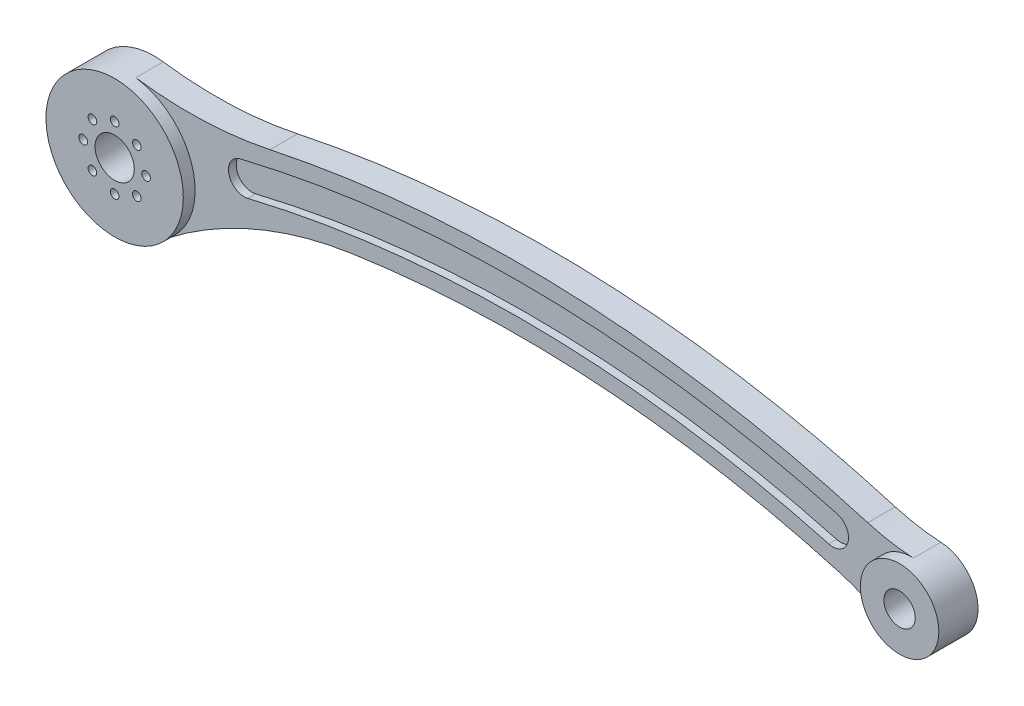
from build123d import *

# Parameters (mm, degrees)
SKETCH1_R                = 5
SKETCH1_R_2              = 4
BOSS_EXTRUDE1_DEPTH      = 10
FILLET1_R                = 100
FILLET3_R                = 50
BOSS_EXTRUDE2_DEPTH      = 5
CUT_EXTRUDE1_DEPTH       = 3
M2_CLEARANCE_HOLE2_D     = 2.2
M2_CLEARANCE_HOLE2_DEPTH = 10


with BuildPart() as part:
    # Sketch1 → Boss-Extrude1 (new body)
    with BuildSketch(Plane.XY):
        with BuildLine():
            ThreePointArc((12.332289397, 12.416305338), (-16.645203494, -5.40251799), (17.2733755, -2.807222621))
            ThreePointArc((17.2733755, -2.807222621), (104.699737116, 9.220908362), (191.757044964, -5.238337488))
            ThreePointArc((191.757044964, -5.238337488), (209.474645485, -2.773362317), (196.872940476, 9.922562291))
            ThreePointArc((196.872940476, 9.922562291), (104.792499107, 25.221141559), (12.332289397, 12.416305338))
        make_face()
        Circle(SKETCH1_R, mode=Mode.SUBTRACT)
        with Locations((199.999550741, 0.423914585)):
            Circle(SKETCH1_R_2, mode=Mode.SUBTRACT)
        with BuildLine():
            ThreePointArc((30.935149345, 4.991193321), (105.08187222, 13.215793431), (178.947951069, 2.766728612))
            ThreePointArc((178.947951069, 2.766728612), (183.85884318, 5.57442138), (181.051150412, 10.485313491))
            ThreePointArc((181.051150412, 10.485313491), (105.20208958, 21.214890117), (29.064850655, 12.769495373))
            ThreePointArc((29.064850655, 12.769495373), (26.110848974, 7.945195001), (30.935149345, 4.991193321))
        make_face(mode=Mode.SUBTRACT)
    extrude(amount=BOSS_EXTRUDE1_DEPTH)

    # Fillet1
    fillet1_edges = [part.edges().sort_by_distance(p)[0] for p in [
        (17.2733755, -2.807222621, 5),
        (12.332289397, 12.416305338, 5),
    ]]
    fillet(fillet1_edges, radius=FILLET1_R)

    # Fillet3
    fillet3_edges = [part.edges().sort_by_distance(p)[0] for p in [
        (196.872940476, 9.922562291, 5),
        (191.757044964, -5.238337488, 5),
    ]]
    fillet(fillet3_edges, radius=FILLET3_R)

    # Sketch2 → Boss-Extrude2 (add)
    with BuildSketch(Plane(origin=(0, 0, 0), x_dir=(-1, 0, 0), z_dir=(0, 0, -1))):
        with BuildLine():
            ThreePointArc((-30.935149345, 4.991193321), (-26.110848974, 7.945195001), (-29.064850655, 12.769495373))
            ThreePointArc((-29.064850655, 12.769495373), (-105.20208958, 21.214890117), (-181.051150412, 10.485313491))
            ThreePointArc((-181.051150412, 10.485313491), (-183.85884318, 5.57442138), (-178.947951069, 2.766728612))
            ThreePointArc((-178.947951069, 2.766728612), (-105.08187222, 13.215793431), (-30.935149345, 4.991193321))
        make_face()
    extrude(amount=-BOSS_EXTRUDE2_DEPTH)

    # Sketch3 → Cut-Extrude1 (cut)
    with BuildSketch(Plane.XY.offset(10)):
        with BuildLine():
            ThreePointArc((10.719889508, -13.832352256), (16.904607487, 4.525952466), (2.374455951, 17.338164809))
            ThreePointArc((2.374455951, 17.338164809), (19.536178227, 16.477975853), (36.591800033, 18.568526337))
            ThreePointArc((36.591800033, 18.568526337), (113.1236291, 24.996521405), (188.887012749, 12.412814518))
            ThreePointArc((188.887012749, 12.412814518), (194.644535138, 11.067035799), (200.520666376, 10.410327279))
            ThreePointArc((200.520666376, 10.410327279), (190.475667826, 3.472792121), (194.624244359, -8.008527607))
            ThreePointArc((194.624244359, -8.008527607), (188.279056755, -4.580565267), (181.506715916, -2.10110341))
            ThreePointArc((181.506715916, -2.10110341), (119.798948798, 8.622149082), (57.220022333, 6.030888954))
            ThreePointArc((57.220022333, 6.030888954), (32.693746361, -0.913106752), (10.719889508, -13.832352256))
        make_face()
    extrude(amount=-CUT_EXTRUDE1_DEPTH, mode=Mode.SUBTRACT)

    # M2 Clearance Hole2
    with Locations(Plane.XY.offset(10)):
        with Locations((0, 8), (5.656854249, 5.656854249), (8, 0), (5.656854249, -5.656854249), (0, -8), (-5.656854249, -5.656854249), (-8, 0), (-5.656854249, 5.656854249)):
            Hole(M2_CLEARANCE_HOLE2_D / 2, depth=M2_CLEARANCE_HOLE2_DEPTH)


solid = part.part
